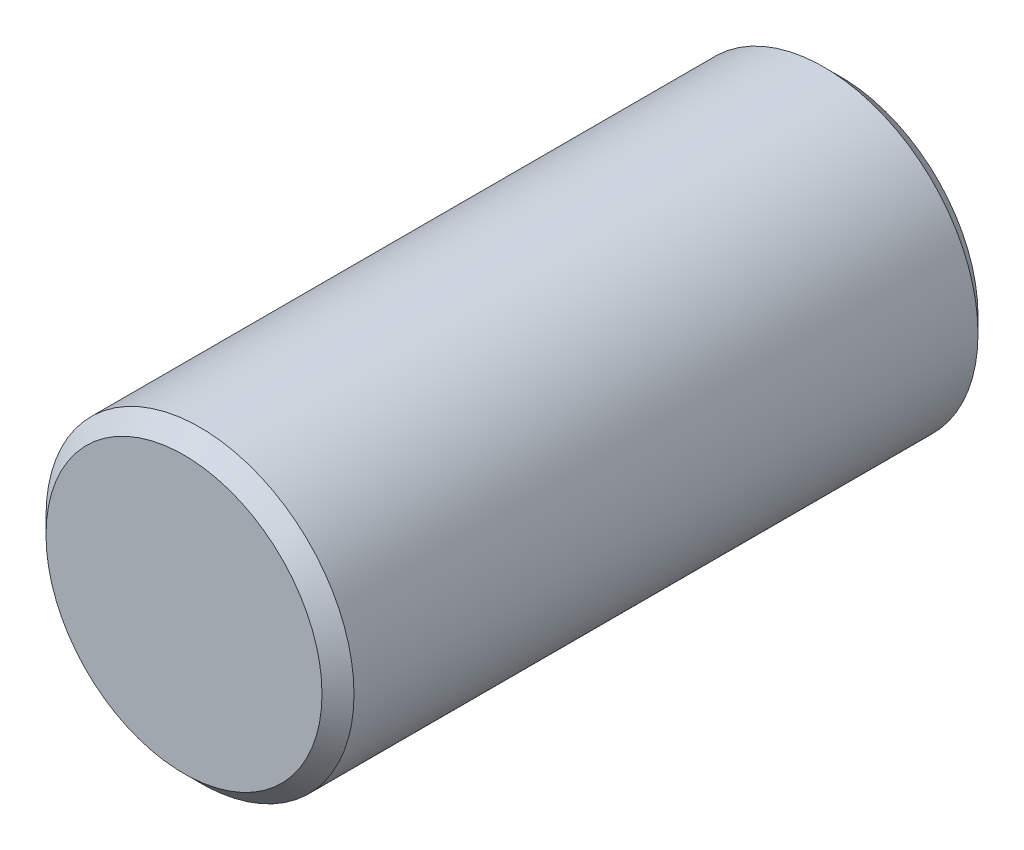
from build123d import *

# Parameters (mm, degrees)
SKETCH1_R           = 19.25
BOSS_EXTRUDE1_DEPTH = 41
CHAMFER1_SIZE       = 2


with BuildPart() as part:
    # Sketch1 → Boss-Extrude1 (new body, symmetric)
    with BuildSketch(Plane.XY):
        Circle(SKETCH1_R)
    extrude(amount=BOSS_EXTRUDE1_DEPTH, both=True)

    # Chamfer1
    chamfer1_edges = [part.edges().sort_by_distance(p)[0] for p in [
        (-19.25, 0, -41),
        (-19.25, 0, 41),
    ]]
    chamfer(chamfer1_edges, length=CHAMFER1_SIZE)


solid = part.part
